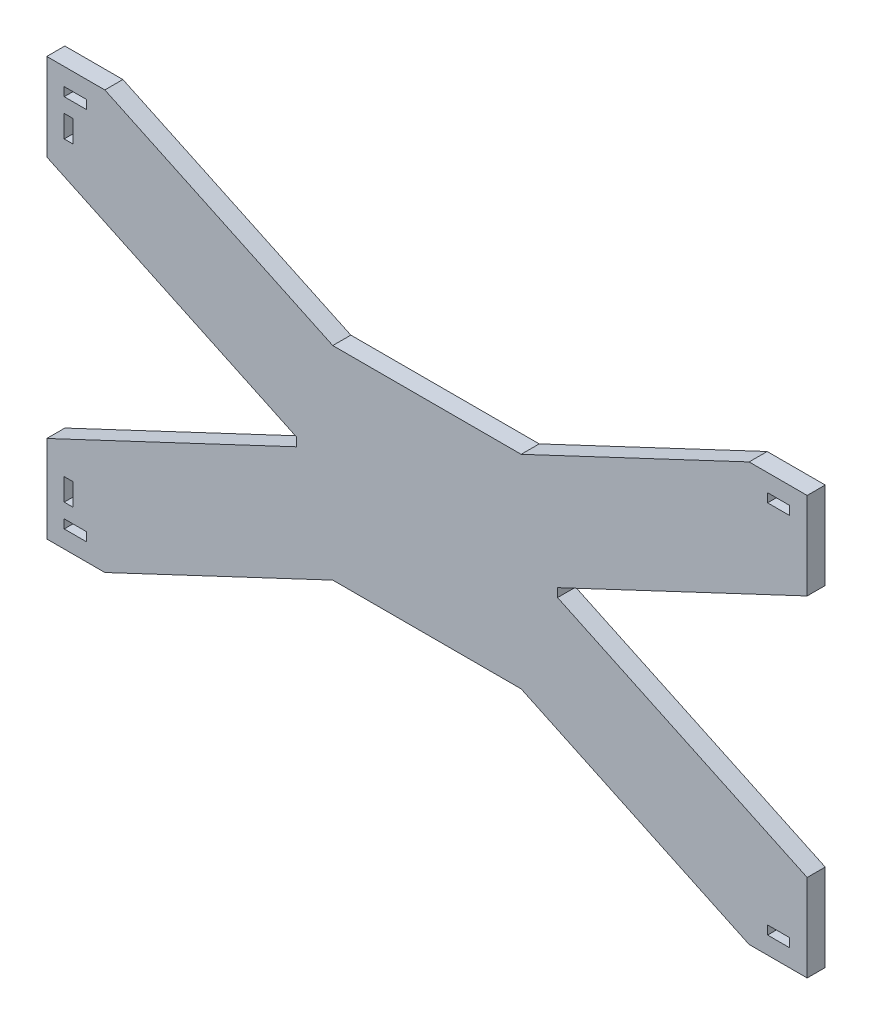
from build123d import *

# Parameters (mm, degrees)
SKETCH1_W           = 1.51
SKETCH1_H           = 3.81
SKETCH1_W_2         = 3.81
SKETCH1_H_2         = 1.51
BOSS_EXTRUDE1_DEPTH = 3.1115


with BuildPart() as part:
    # Sketch1 → Boss-Extrude1 (new body)
    with BuildSketch(Plane.XY):
        Polygon((-64.76864758, -36.358763528), (-54.76864758, -36.358763528), (-15.496717756, -17.858763528), (16.959422595, -17.858763528), (56.23135242, -36.358763528), (66.23135242, -36.358763528), (66.23135242, -21.358763528), (23.23135242, -1.102565181), (23.23135242, 0.385038125), (66.23135242, 20.641236472), (66.23135242, 35.641236472), (56.23135242, 35.641236472), (16.959422595, 17.141236472), (-15.496717756, 17.141236472), (-54.76864758, 35.641236472), (-64.76864758, 35.641236472), (-64.76864758, 20.641236472), (-21.76864758, 0.385038125), (-21.76864758, -1.102565181), (-64.76864758, -21.358763528), align=None)
        with Locations((-61.01364758, 26.736236472)):
            Rectangle(SKETCH1_W, SKETCH1_H, mode=Mode.SUBTRACT)
        with Locations((-61.01364758, -27.453763528)):
            Rectangle(SKETCH1_W, SKETCH1_H, mode=Mode.SUBTRACT)
        with Locations((-59.86364758, 31.886236472)):
            Rectangle(SKETCH1_W_2, SKETCH1_H_2, mode=Mode.SUBTRACT)
        with Locations((-59.86364758, -32.603763528)):
            Rectangle(SKETCH1_W_2, SKETCH1_H_2, mode=Mode.SUBTRACT)
        with Locations((61.32635242, 31.886236472)):
            Rectangle(SKETCH1_W_2, SKETCH1_H_2, mode=Mode.SUBTRACT)
        with Locations((61.32635242, -32.603763528)):
            Rectangle(SKETCH1_W_2, SKETCH1_H_2, mode=Mode.SUBTRACT)
    extrude(amount=BOSS_EXTRUDE1_DEPTH)


solid = part.part
